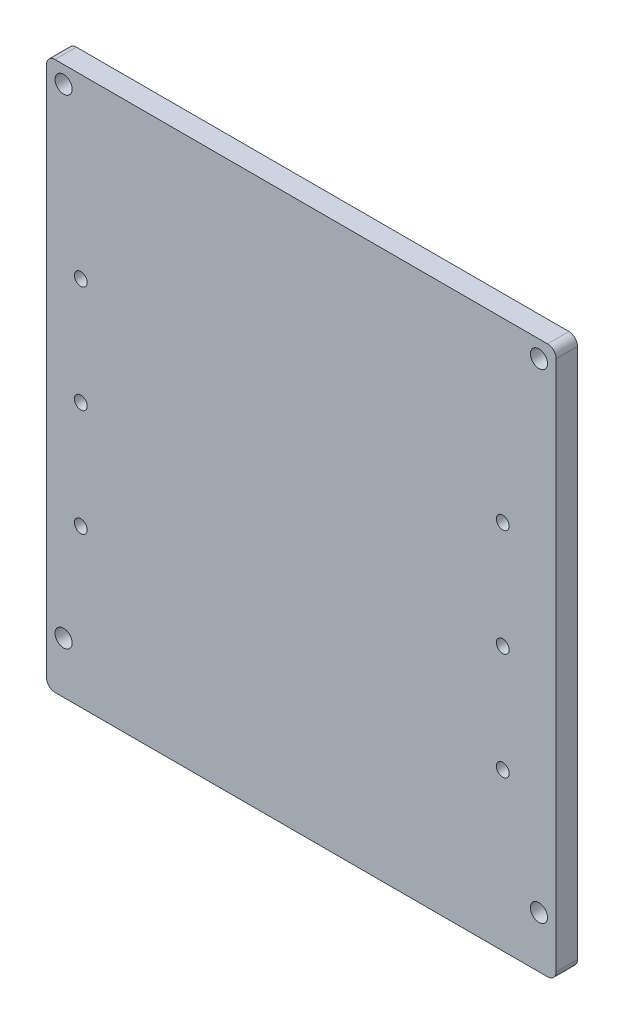
from build123d import *

# Parameters (mm, degrees)
SKETCH_1_R          = 2
EXTRUDE_1_DEPTH     = 5
SKETCH_5_R          = 1.5
SKETCH_5_W          = 16.1
SKETCH_5_H          = 16.1
CUT_EXTRUDE_1_DEPTH = 4
EXTRUDE_2_DEPTH     = 5
FILLET_1_R          = 2
SKETCH_9_R          = 1.5
CUT_EXTRUDE_2_DEPTH = 10


with BuildPart() as part:
    # 草图1 → 凸台-拉伸1 (new body)
    with BuildSketch(Plane.XY):
        with BuildLine():
            Line((62.7093167, -58.345136948), (62.7093167, 57.654863052))
            ThreePointArc((62.7093167, 57.654863052), (62.123530262, 59.069076614), (60.7093167, 59.654863052))
            Line((60.7093167, 59.654863052), (-54.2906833, 59.654863052))
            ThreePointArc((-54.2906833, 59.654863052), (-55.704896862, 59.069076614), (-56.2906833, 57.654863052))
            Line((-56.2906833, 57.654863052), (-56.2906833, -58.345136948))
            ThreePointArc((-56.2906833, -58.345136948), (-55.704896862, -59.759350511), (-54.2906833, -60.345136948))
            Line((-54.2906833, -60.345136948), (60.7093167, -60.345136948))
            ThreePointArc((60.7093167, -60.345136948), (62.123530262, -59.759350511), (62.7093167, -58.345136948))
        make_face()
        with Locations((-52.2906833, -56.345136948)):
            Circle(SKETCH_1_R, mode=Mode.SUBTRACT)
        with Locations((58.7093167, -56.345136948)):
            Circle(SKETCH_1_R, mode=Mode.SUBTRACT)
        with Locations((58.7093167, 55.654863052)):
            Circle(SKETCH_1_R, mode=Mode.SUBTRACT)
        with Locations((-52.2906833, 55.654863052)):
            Circle(SKETCH_1_R, mode=Mode.SUBTRACT)
    extrude(amount=EXTRUDE_1_DEPTH)

    # 草图5 → 切除-拉伸1 (cut, through all)
    with BuildSketch(Plane.XY.offset(3)):
        with Locations((-48.275635297, 18.301860934)):
            Circle(SKETCH_5_R)
        with Locations((50.252991339, 18.301860934)):
            Circle(SKETCH_5_R)
        with Locations((-48.275635297, -6.698139066)):
            Circle(SKETCH_5_R)
        with Locations((50.252991339, -6.698139066)):
            Circle(SKETCH_5_R)
        with Locations((-48.275635297, -31.698139066)):
            Circle(SKETCH_5_R)
        with Locations((50.252991339, -31.698139066)):
            Circle(SKETCH_5_R)
        with Locations((25.214825615, -7.576393001)):
            Rectangle(SKETCH_5_W, SKETCH_5_H)
        with Locations((25.214825615, 14.423606999)):
            Rectangle(SKETCH_5_W, SKETCH_5_H)
        with Locations((3.214825615, -7.576393001)):
            Rectangle(SKETCH_5_W, SKETCH_5_H)
        with Locations((-18.785174385, 14.423606999)):
            Rectangle(SKETCH_5_W, SKETCH_5_H)
        with Locations((-18.785174385, -7.576393001)):
            Rectangle(SKETCH_5_W, SKETCH_5_H)
        with Locations((-18.785174385, -29.576393001)):
            Rectangle(SKETCH_5_W, SKETCH_5_H)
        with Locations((3.214825615, 14.423606999)):
            Rectangle(SKETCH_5_W, SKETCH_5_H)
        with Locations((3.214825615, -29.576393001)):
            Rectangle(SKETCH_5_W, SKETCH_5_H)
        with Locations((25.214825615, -29.576393001)):
            Rectangle(SKETCH_5_W, SKETCH_5_H)
        with Locations((25.214825615, -50.576393001)):
            Rectangle(SKETCH_5_W, SKETCH_5_H)
        with Locations((3.214825615, -50.576393001)):
            Rectangle(SKETCH_5_W, SKETCH_5_H)
        with Locations((-18.785174385, -50.576393001)):
            Rectangle(SKETCH_5_W, SKETCH_5_H)
    extrude(amount=-CUT_EXTRUDE_1_DEPTH, mode=Mode.SUBTRACT)

    # 草图8 → 凸台-拉伸2 (add)
    with BuildSketch(Plane.XY.offset(5)):
        Polygon((-56.2906833, -58.345136948), (-26.835174385, -58.345136948), (-26.835174385, -60.345136948), (33.264825615, -60.345136948), (33.264825615, -58.345136948), (62.7093167, -58.345136948), (62.7093167, -68.345136948), (33.264825615, -68.345136948), (-26.835174385, -68.345136948), (-56.2906833, -68.345136948), align=None)
    extrude(amount=-EXTRUDE_2_DEPTH)

    # 圆角1
    fillet_1_edges = [part.edges().sort_by_distance(p)[0] for p in [
        (-56.2906833, -68.345136948, 2.5),
        (62.7093167, -68.345136948, 2.5),
    ]]
    fillet(fillet_1_edges, radius=FILLET_1_R)

    # 草图9 → 切除-拉伸2 (cut)
    with BuildSketch(Plane(origin=(0, 0, 0), x_dir=(-1, 0, 0), z_dir=(0, 0, -1))):
        with Locations((-50.252991339, -6.698139066)):
            Circle(SKETCH_9_R)
        with Locations((-50.252991339, -31.698139066)):
            Circle(SKETCH_9_R)
        with Locations((48.275635297, -31.698139066)):
            Circle(SKETCH_9_R)
        with Locations((48.275635297, -6.698139066)):
            Circle(SKETCH_9_R)
        with Locations((48.275635297, 18.301860934)):
            Circle(SKETCH_9_R)
        with Locations((-50.252991339, 18.301860934)):
            Circle(SKETCH_9_R)
    extrude(amount=-CUT_EXTRUDE_2_DEPTH, mode=Mode.SUBTRACT)


solid = part.part
